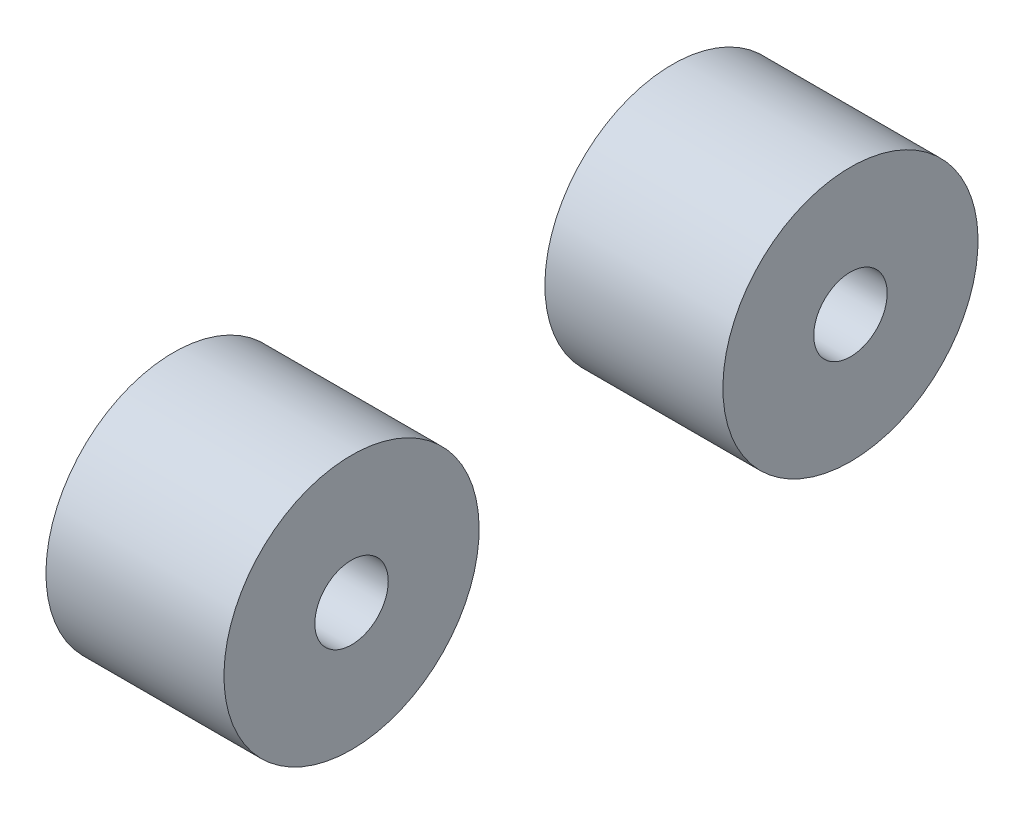
from build123d import *

# Parameters (mm, degrees)
SKETCH1_W          = 18
SKETCH1_H          = 12.9
SKETCH2_R          = 3.71375
CUT_EXTRUDE1_DEPTH = 7.5725
SKETCH4_R          = 3.71375
CUT_EXTRUDE2_DEPTH = 7.0725


with BuildPart() as part:
    # Sketch1 → Revolve1 (revolve)
    with BuildSketch(Plane.XY):
        with Locations((17.255, 6.45)):
            Rectangle(SKETCH1_W, SKETCH1_H)
    revolve(axis=Axis((8.255, 0, 0), (1, 0, 0)))

    # Sketch2 → Cut-Extrude1 (cut)
    with BuildSketch(Plane.ZY.offset(-8.255)):
        Circle(SKETCH2_R)
    extrude(amount=-CUT_EXTRUDE1_DEPTH, mode=Mode.SUBTRACT)

    # Sketch4 → Cut-Extrude2 (cut)
    with BuildSketch(Plane(origin=(26.255, 0, 0), x_dir=(0, 0, -1), z_dir=(1, 0, 0))):
        Circle(SKETCH4_R)
    extrude(amount=-CUT_EXTRUDE2_DEPTH, mode=Mode.SUBTRACT)


with BuildPart() as body_2:
    # Body-Move/Copy1: copy of part
    add(part.part.moved(Location((0, 0, 50.452769062))))


solid = Compound([part.part, body_2.part])
